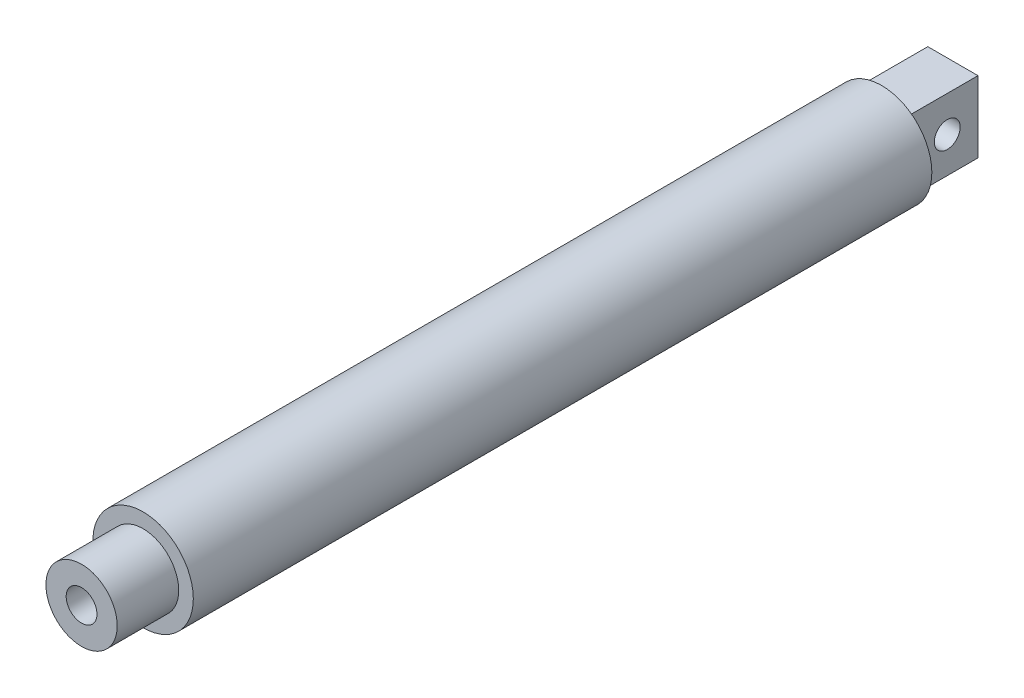
from build123d import *

# Parameters (mm, degrees)
SKETCH1_R           = 7.874
BOSS_EXTRUDE1_DEPTH = 115.824
SKETCH2_R           = 5.588
BOSS_EXTRUDE2_DEPTH = 9.652
SKETCH3_W           = 7.874
SKETCH3_H           = 11.176
BOSS_EXTRUDE3_DEPTH = 11.176
SKETCH4_R           = 2.032
CUT_EXTRUDE1_DEPTH  = 12.811
SKETCH5_R           = 2.413
CUT_EXTRUDE2_DEPTH  = 114.3


with BuildPart() as part:
    # Sketch1 → Boss-Extrude1 (new body)
    with BuildSketch(Plane.XY):
        Circle(SKETCH1_R)
    extrude(amount=BOSS_EXTRUDE1_DEPTH)

    # Sketch2 → Boss-Extrude2 (add)
    with BuildSketch(Plane.XY.offset(115.824)):
        Circle(SKETCH2_R)
    extrude(amount=BOSS_EXTRUDE2_DEPTH)

    # Sketch3 → Boss-Extrude3 (add)
    with BuildSketch(Plane(origin=(0, 0, 0), x_dir=(-1, 0, 0), z_dir=(0, 0, -1))):
        Rectangle(SKETCH3_W, SKETCH3_H)
    extrude(amount=BOSS_EXTRUDE3_DEPTH)

    # Sketch4 → Cut-Extrude1 (cut, through all)
    with BuildSketch(Plane(origin=(3.937, 0, 0), x_dir=(0, 0, -1), z_dir=(1, 0, 0))):
        with Locations((6.35, 0)):
            Circle(SKETCH4_R)
    extrude(amount=-CUT_EXTRUDE1_DEPTH, mode=Mode.SUBTRACT)

    # Sketch5 → Cut-Extrude2 (cut)
    with BuildSketch(Plane.XY.offset(125.476)):
        Circle(SKETCH5_R)
    extrude(amount=-CUT_EXTRUDE2_DEPTH, mode=Mode.SUBTRACT)


solid = part.part
